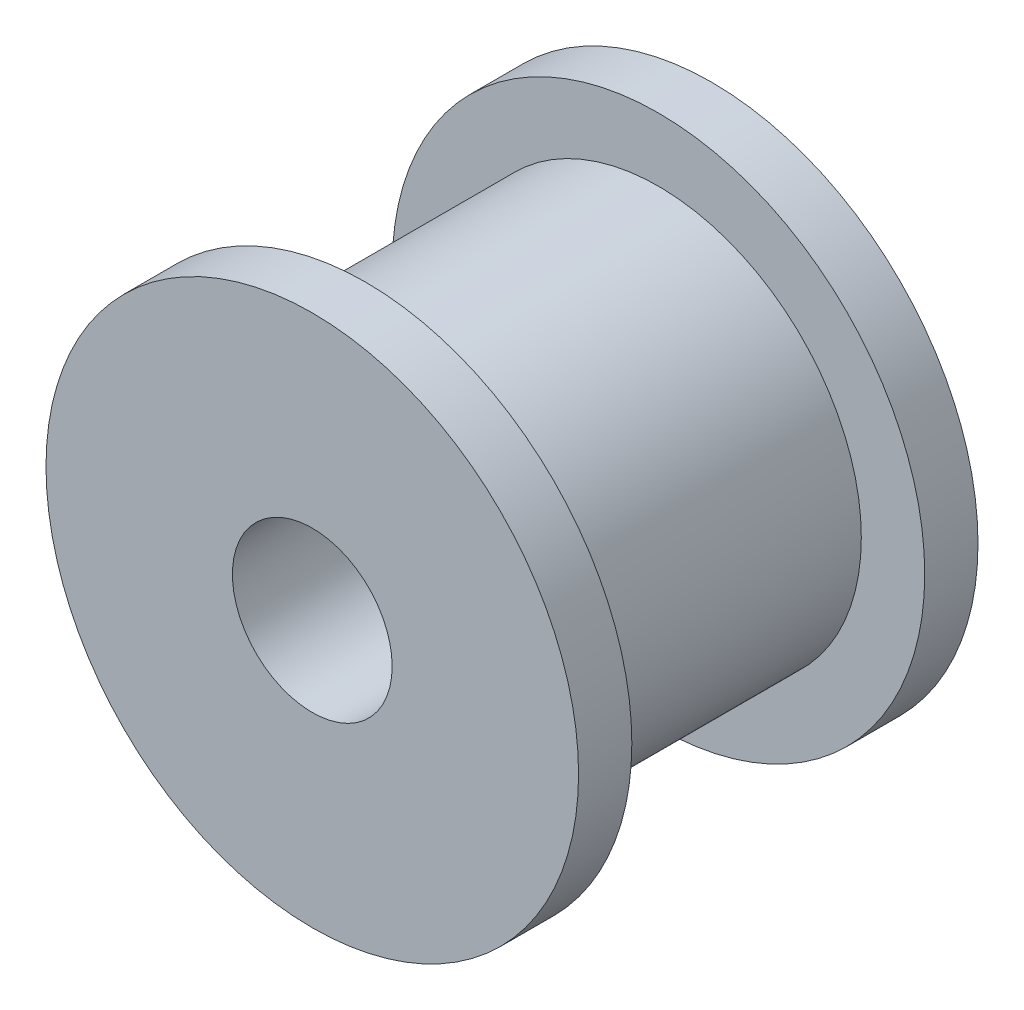
from build123d import *

# Parameters (mm, degrees)
SKETCH1_R           = 10
SKETCH1_R_2         = 3
BOSS_EXTRUDE1_DEPTH = 15
CUT_EXTRUDE1_START  = -2
SKETCH2_R           = 10.003270656
SKETCH2_R_2         = 7.618419173
CUT_EXTRUDE1_DEPTH  = 11


with BuildPart() as part:
    # Sketch1 → Boss-Extrude1 (new body)
    with BuildSketch(Plane.XY):
        Circle(SKETCH1_R)
        Circle(SKETCH1_R_2, mode=Mode.SUBTRACT)
    extrude(amount=BOSS_EXTRUDE1_DEPTH)

    # Sketch2 → Cut-Extrude1 (cut)
    with BuildSketch(Plane.XY.offset(15).offset(CUT_EXTRUDE1_START)):
        Circle(SKETCH2_R)
        Circle(SKETCH2_R_2, mode=Mode.SUBTRACT)
    extrude(amount=-CUT_EXTRUDE1_DEPTH, mode=Mode.SUBTRACT)


solid = part.part
